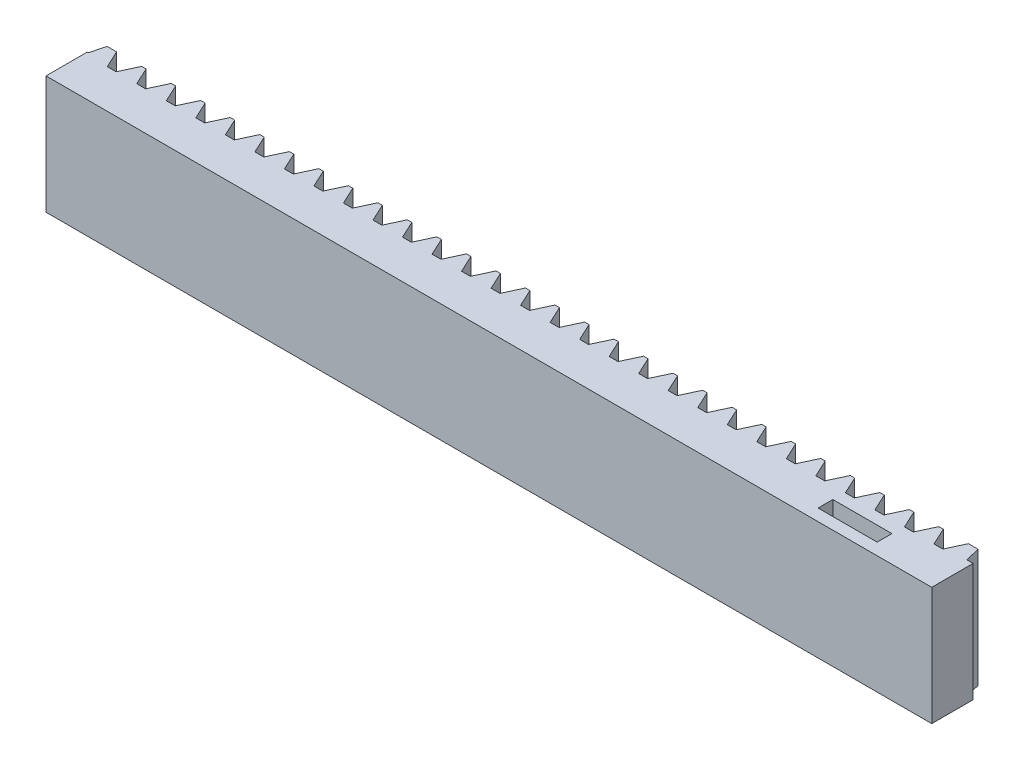
from build123d import *

# Parameters (mm, degrees)
SKETCH_1_W               = 60
SKETCH_1_H               = 10
EXTRUDE_1_DEPTH          = 2.8
EXTRUDE_2_DEPTH          = 5
PATTERN_LINEAR_1_COUNT   = 30
PATTERN_LINEAR_1_PITCH   = 2
CUT_EXTRUDE_1_DEPTH      = 10.1
PATTERN_LINEAR_2_COUNT   = 29
PATTERN_LINEAR_2_PITCH   = 2
CUT_EXTRUDE_4_DEPTH      = 5
CUT_EXTRUDE_4_DEPTH_BACK = 5
SKETCH_5_W               = 60
SKETCH_5_H               = 1
CUT_EXTRUDE_5_DEPTH      = 10
CUT_EXTRUDE_5_DEPTH_BACK = 10
SKETCH_6_W               = 4
SKETCH_6_H               = 1


with BuildPart() as part:
    # 草圖1 → 填料-伸長1 (new body)
    with BuildSketch(Plane.XY):
        with Locations((17.035714286, 0.035714286)):
            Rectangle(SKETCH_1_W, SKETCH_1_H)
    extrude(amount=EXTRUDE_1_DEPTH)

    # 草圖3 → 填料-伸長2 (add, symmetric)
    with BuildSketch(Plane(origin=(0, 0, 0), x_dir=(1, 0, 0), z_dir=(0, 1, 0))):
        Polygon((-12.88158197, 0), (-11.38158197, 0), (-11.63158197, 1), (-12.63158197, 1), align=None)
    extrude_2 = extrude(amount=EXTRUDE_2_DEPTH, both=True)

    # 直線複製排列1: 填料-伸長2 ×30
    with Locations(*[(i * PATTERN_LINEAR_1_PITCH, 0, 0) for i in range(1, PATTERN_LINEAR_1_COUNT)]):
        add(extrude_2)

    # 草圖4 → 除料-伸長1 (cut)
    with BuildSketch(Plane(origin=(0, 5.035714286, 0), x_dir=(1, 0, 0), z_dir=(0, 1, 0))):
        Polygon((-11.51663584, 0), (-11.431760496, -0.182548771), (-10.831403444, -0.182548771), (-10.746528099, 0), (-10.28158197, 1), (-11.98158197, 1), align=None)
    cut_extrude_1 = extrude(amount=-CUT_EXTRUDE_1_DEPTH, mode=Mode.SUBTRACT)

    # 直線複製排列2: 除料-伸長1 ×29
    with Locations(*[(i * PATTERN_LINEAR_2_PITCH, 0, 0) for i in range(1, PATTERN_LINEAR_2_COUNT)]):
        add(cut_extrude_1, mode=Mode.SUBTRACT)

    # 草圖5 → 除料-伸長4 (cut, two sides: drawn at the far end of the back side and taken through both)
    with BuildSketch(Plane.XY.offset(-CUT_EXTRUDE_4_DEPTH_BACK)):
        Polygon((-12.964285714, -3.964285714), (-12.964285714, -4.964285714), (-12.964285714, -5.413989132), (47.035714286, -5.088807164), (47.035714286, -3.964285714), align=None)
        with Locations((17.035714286, 4.535714286)):
            Rectangle(SKETCH_5_W, SKETCH_5_H)
    extrude(amount=CUT_EXTRUDE_4_DEPTH + CUT_EXTRUDE_4_DEPTH_BACK, mode=Mode.SUBTRACT)

    # 草圖6 → 除料-伸長5 (cut, two sides: drawn at the far end of the back side and taken through both)
    with BuildSketch(Plane(origin=(0, 4.035714286, 0), x_dir=(1, 0, 0), z_dir=(0, 1, 0)).offset(-CUT_EXTRUDE_5_DEPTH_BACK)):
        with Locations((40.535714286, -1.5)):
            Rectangle(SKETCH_6_W, SKETCH_6_H)
    extrude(amount=CUT_EXTRUDE_5_DEPTH + CUT_EXTRUDE_5_DEPTH_BACK, mode=Mode.SUBTRACT)


solid = part.part
